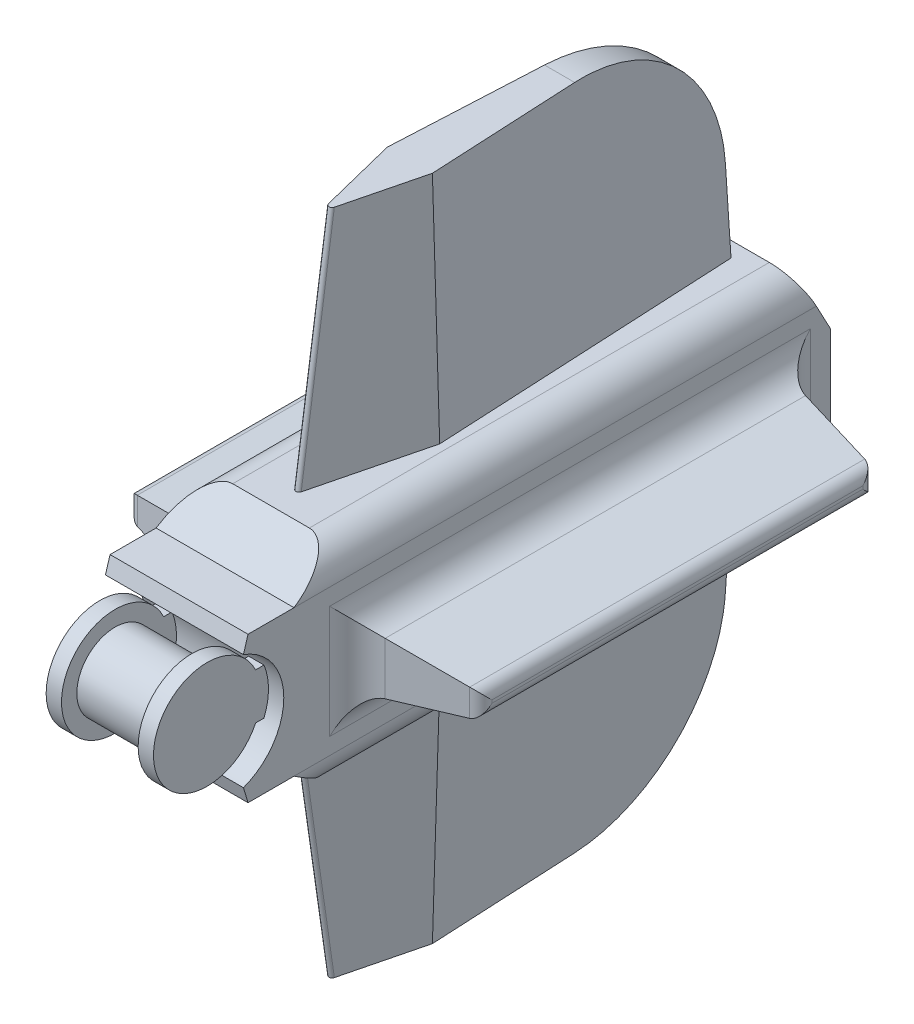
from build123d import *

# Parameters (mm, degrees)
SKETCH1_R                = 3.175
BOSS_EXTRUDE1_DEPTH      = 3.175
SKETCH2_R                = 4.445
BOSS_EXTRUDE2_DEPTH      = 1.27
SKETCH3_W                = 6.35
SKETCH3_H                = 3.81
BOSS_EXTRUDE3_DEPTH      = 1.27
BOSS_EXTRUDE4_DEPTH      = 8.89
BOSS_EXTRUDE4_DEPTH_BACK = 2.54
SKETCH5_R                = 3.175
CUT_EXTRUDE1_DEPTH       = 12.7
FILLET1_R                = 2.54
SKETCH6_W                = 35.56
SKETCH6_H                = 5.08
BOSS_EXTRUDE5_DEPTH      = 8.89
BOSS_EXTRUDE5_TAPER      = 10
FILLET2_R                = 1.016
FILLET3_R                = 2.54
BOSS_EXTRUDE6_DEPTH      = 19.05
BOSS_EXTRUDE6_TAPER      = 2
FILLET4_R                = 0.254
FILLET5_R                = 12.7


with BuildPart() as part:
    # Sketch1 → Boss-Extrude1 (new body, symmetric)
    with BuildSketch(Plane(origin=(0, 0, 0), x_dir=(0, 0, -1), z_dir=(1, 0, 0))):
        Circle(SKETCH1_R)
    extrude(amount=BOSS_EXTRUDE1_DEPTH, both=True)

    # Sketch2 → Boss-Extrude2 (add)
    with BuildSketch(Plane(origin=(3.175, 0, 0), x_dir=(0, 0, -1), z_dir=(1, 0, 0))):
        Circle(SKETCH2_R)
    boss_extrude2 = extrude(amount=BOSS_EXTRUDE2_DEPTH)

    # Mirror1: Boss-Extrude2 across plane
    add(boss_extrude2.mirror(Plane(origin=(0, 0, 0), x_dir=(0, 0, 1), z_dir=(1, 0, 0))))

    # Sketch3 → Boss-Extrude3 (add)
    with BuildSketch(Plane(origin=(4.445, 0, 0), x_dir=(0, 0, -1), z_dir=(1, 0, 0))):
        with Locations((3.175, 0)):
            Rectangle(SKETCH3_W, SKETCH3_H)
    boss_extrude3 = extrude(amount=-BOSS_EXTRUDE3_DEPTH)

    # Mirror2: Boss-Extrude3 across plane
    add(boss_extrude3.mirror(Plane(origin=(0, 0, 0), x_dir=(0, 0, 1), z_dir=(1, 0, 0))))

    # Sketch4 → Boss-Extrude4 (add, two sides)
    with BuildSketch(Plane(origin=(-3.175, 0, 0), x_dir=(0, 0, -1), z_dir=(1, 0, 0))) as boss_extrude4_sk:
        with BuildLine():
            Line((1.737462328, 4.773638514), (2.118462328, 6.043638514))
            Line((2.118462328, 6.043638514), (5.928462328, 6.043638514))
            Line((5.928462328, 6.043638514), (9.738462328, 8.583638514))
            Line((9.738462328, 8.583638514), (47.838462328, 8.583638514))
            Line((47.838462328, 8.583638514), (50.378462328, 3.81))
            Line((50.378462328, 3.81), (50.378462328, -3.81))
            Line((50.378462328, -3.81), (47.838462328, -8.583638514))
            Line((47.838462328, -8.583638514), (9.738462328, -8.583638514))
            Line((9.738462328, -8.583638514), (5.928462328, -6.043638514))
            Line((5.928462328, -6.043638514), (2.118462328, -6.043638514))
            Line((2.118462328, -6.043638514), (1.737462328, -4.773638514))
            ThreePointArc((1.737462328, -4.773638514), (5.08, 0), (1.737462328, 4.773638514))
        make_face()
    extrude(amount=BOSS_EXTRUDE4_DEPTH)
    extrude(boss_extrude4_sk.sketch, amount=-BOSS_EXTRUDE4_DEPTH_BACK)

    # Sketch5 → Cut-Extrude1 (cut)
    with BuildSketch(Plane(origin=(0, 0, -50.378462328), x_dir=(-1, 0, 0), z_dir=(0, 0, -1))):
        Circle(SKETCH5_R)
    extrude(amount=-CUT_EXTRUDE1_DEPTH, mode=Mode.SUBTRACT)

    # Fillet1
    fillet1_edges = [part.edges().sort_by_distance(p)[0] for p in [
        (5.715, -8.583638514, -28.788462328),
        (-5.715, -8.583638514, -28.788462328),
        (-5.715, 8.583638514, -28.788462328),
        (5.715, 8.583638514, -28.788462328),
    ]]
    fillet(fillet1_edges, radius=FILLET1_R)

    # Sketch6 → Boss-Extrude5 (add)
    with BuildSketch(Plane(origin=(5.715, 0, 0), x_dir=(0, 0, -1), z_dir=(1, 0, 0))):
        with Locations((28.788462328, 0)):
            Rectangle(SKETCH6_W, SKETCH6_H)
    boss_extrude5 = extrude(amount=BOSS_EXTRUDE5_DEPTH, taper=BOSS_EXTRUDE5_TAPER)

    # Mirror3: Boss-Extrude5 across plane
    add(boss_extrude5.mirror(Plane(origin=(0, 0, 0), x_dir=(0, 0, 1), z_dir=(1, 0, 0))))

    # Fillet2
    fillet2_edges = [part.edges().sort_by_distance(p)[0] for p in [
        (14.605, 0, -12.576009187),
        (14.605, -0.972453142, -28.788462328),
        (14.605, 0, -45.00091547),
        (14.605, 0.972453142, -28.788462328),
        (-14.605, 0, -12.576009187),
        (-14.605, 0.972453142, -28.788462328),
        (-14.605, 0, -45.00091547),
        (-14.605, -0.972453142, -28.788462328),
    ]]
    fillet(fillet2_edges, radius=FILLET2_R)

    # Fillet3
    fillet3_edges = [part.edges().sort_by_distance(p)[0] for p in [
        (5.715, 0, -11.008462328),
        (5.715, -2.54, -28.788462328),
        (5.715, 0, -46.568462328),
        (5.715, 2.54, -28.788462328),
        (-5.715, 0, -11.008462328),
        (-5.715, -2.54, -28.788462328),
        (-5.715, 0, -46.568462328),
        (-5.715, 2.54, -28.788462328),
    ]]
    fillet(fillet3_edges, radius=FILLET3_R)

    # Sketch7 → Boss-Extrude6 (add)
    with BuildSketch(Plane(origin=(0, 8.583638514, 0), x_dir=(1, 0, 0), z_dir=(0, 1, 0))):
        Polygon((-1.27, 46.568462328), (-2.54, 21.168462328), (0, 11.008462328), (2.54, 21.168462328), (1.27, 46.568462328), align=None)
    boss_extrude6 = extrude(amount=BOSS_EXTRUDE6_DEPTH, taper=BOSS_EXTRUDE6_TAPER)

    # Mirror4: Boss-Extrude6 across plane
    add(boss_extrude6.mirror(Plane.ZX))

    # Fillet4
    fillet4_edges = [part.edges().sort_by_distance(p)[0] for p in [
        (0, 18.108638514, -12.379891079),
        (0, -18.108638514, -12.379891079),
    ]]
    fillet(fillet4_edges, radius=FILLET4_R)

    # Fillet5
    fillet5_edges = [part.edges().sort_by_distance(p)[0] for p in [
        (0, 27.633638514, -45.903221669),
        (0, -27.633638514, -45.903221669),
    ]]
    fillet(fillet5_edges, radius=FILLET5_R)


solid = part.part
